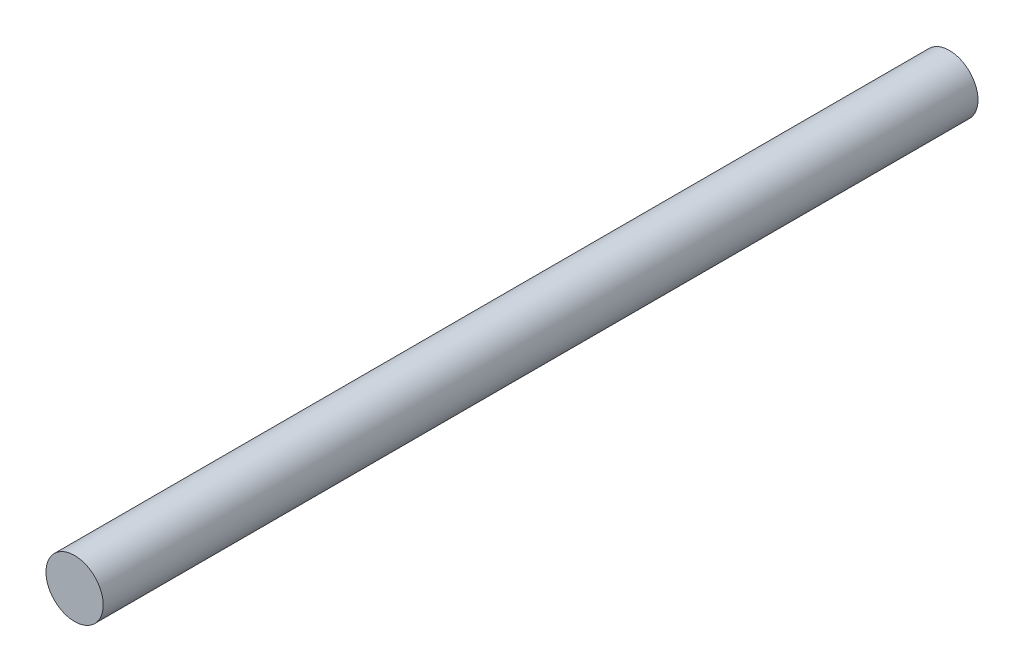
from build123d import *

# Parameters (mm, degrees)
SKETCH1_R           = 3.175
BOSS_EXTRUDE1_DEPTH = 48.5


with BuildPart() as part:
    # Sketch1 → Boss-Extrude1 (new body, symmetric)
    with BuildSketch(Plane.XY):
        Circle(SKETCH1_R)
    extrude(amount=BOSS_EXTRUDE1_DEPTH, both=True)


solid = part.part
